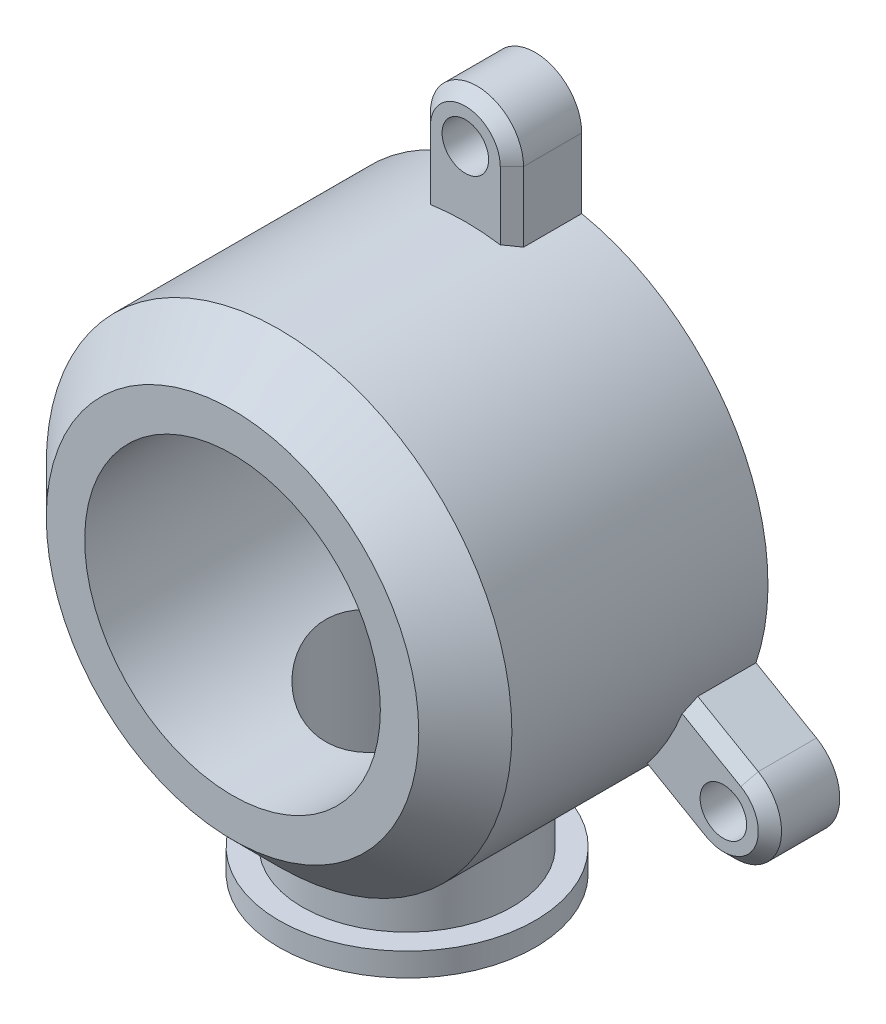
from build123d import *

# Parameters (mm, degrees)
BOSS_EXTRUDE1_DEPTH          = 65
BOSS_EXTRUDE2_DEPTH          = 25
BOSS_EXTRUDE3_DEPTH          = 15
CHAMFER2_SIZE                = 2.5
F_10_0MM_DOWEL_HOLE1_D       = 10
CIRPATTERN2_COUNT            = 3
CHAMFER2_OF_CIRPATTERN2_SIZE = 2.5
CHAMFER1_SIZE                = 10
SKETCH2_R                    = 27.5
BOSS_EXTRUDE4_DEPTH          = 5
BOSS_EXTRUDE5_REACH          = 164.658
SKETCH3_R                    = 22.5
CUT_EXTRUDE1_REACH           = 168.801
CUT_EXTRUDE1_END_RADIUS      = 31.75
SKETCH4_R                    = 17.5


with BuildPart() as part:
    # Sketch1 → Boss-Extrude1 (new body)
    with BuildSketch(Plane.XY):
        with BuildLine():
            ThreePointArc((10, 48.989794856), (0, 50), (-10, 48.989794856))
            ThreePointArc((-10, 48.989794856), (-31.622776602, -38.729833462), (50, 0))
            ThreePointArc((50, 0), (38.729833462, 31.622776602), (10, 48.989794856))
        make_face()
        with BuildLine():
            ThreePointArc((31.75, 0), (-20.607189279, -24.153804048), (-5, 31.353827518))
            ThreePointArc((-5, 31.353827518), (0, 31.75), (5, 31.353827518))
            ThreePointArc((5, 31.353827518), (24.153804048, 20.607189279), (31.75, 0))
        make_face(mode=Mode.SUBTRACT)
    extrude(amount=BOSS_EXTRUDE1_DEPTH)

    # Sketch1_3 → Boss-Extrude2 (add)
    with BuildSketch(Plane.XY):
        with BuildLine():
            Line((-5, 20.603827518), (5, 20.603827518))
            Line((5, 20.603827518), (5, 31.353827518))
            ThreePointArc((5, 31.353827518), (0, 31.75), (-5, 31.353827518))
            Line((-5, 31.353827518), (-5, 20.603827518))
        make_face()
    extrude(amount=BOSS_EXTRUDE2_DEPTH)

    # Sketch1_4 → Boss-Extrude3 (add)
    with BuildSketch(Plane.XY):
        with BuildLine():
            Line((-10, 63.989794856), (-10, 48.989794856))
            ThreePointArc((-10, 48.989794856), (0, 50), (10, 48.989794856))
            Line((10, 48.989794856), (10, 63.989794856))
            ThreePointArc((10, 63.989794856), (0, 73.989794856), (-10, 63.989794856))
        make_face()
    boss_extrude3 = extrude(amount=BOSS_EXTRUDE3_DEPTH)

    # Chamfer2
    chamfer2_edges = [part.edges().sort_by_distance(p)[0] for p in [
        (-10, 56.489794856, 15),
        (0, 73.989794856, 15),
        (10, 56.489794856, 15),
    ]]
    chamfer(chamfer2_edges, length=CHAMFER2_SIZE)

    # Ø10.0mm Dowel Hole1 (through all)
    with Locations(Plane.XY.offset(15)):
        with Locations((0, 63.989794856)):
            f_10_0mm_dowel_hole1 = Hole(F_10_0MM_DOWEL_HOLE1_D / 2)

    # CirPattern2: Boss-Extrude3, Ø10.0mm Dowel Hole1 ×3 about axis
    cirpattern2_axis = Axis((0, 0, 65), (0, 0, -1))
    add([boss_extrude3.rotate(cirpattern2_axis, i * 360 / CIRPATTERN2_COUNT) for i in range(1, CIRPATTERN2_COUNT)])
    add([f_10_0mm_dowel_hole1.rotate(cirpattern2_axis, i * 360 / CIRPATTERN2_COUNT) for i in range(1, CIRPATTERN2_COUNT)], mode=Mode.SUBTRACT)

    # Chamfer2 of CirPattern2
    chamfer2_of_cirpattern2_edges = [part.edges().sort_by_distance(p)[0] for p in [
        (53.9215974, -19.58464339, 15),
        (64.077041966, -36.994897428, 15),
        (43.9215974, -36.905151466, 15),
        (-43.9215974, -36.905151466, 15),
        (-64.077041966, -36.994897428, 15),
        (-53.9215974, -19.58464339, 15),
    ]]
    chamfer(chamfer2_of_cirpattern2_edges, length=CHAMFER2_OF_CIRPATTERN2_SIZE)

    # Chamfer1
    chamfer1_edges = [part.edges().sort_by_distance(p)[0] for p in [
        (-50, 0, 65),
    ]]
    chamfer(chamfer1_edges, length=CHAMFER1_SIZE)

    # Sketch3 → Boss-Extrude5 (add, up to next)
    with BuildSketch(Plane(origin=(0, -60, 0), x_dir=(1, 0, 0), z_dir=(0, 1, 0)), mode=Mode.PRIVATE) as boss_extrude5_sk1:
        with Locations((0, -27.5)):
            Circle(SKETCH3_R)
    boss_extrude5_tool1 = extrude(boss_extrude5_sk1.sketch, amount=BOSS_EXTRUDE5_REACH, mode=Mode.PRIVATE) - part.part


with BuildPart() as body_2:
    # Sketch2 → Boss-Extrude4 (new body)
    with BuildSketch(Plane(origin=(0, -65, 0), x_dir=(1, 0, 0), z_dir=(0, 1, 0))):
        with Locations((0, -27.5)):
            Circle(SKETCH2_R)
    extrude(amount=BOSS_EXTRUDE4_DEPTH)


with BuildPart() as part_1:
    add(part.part)

    add(body_2.part)  # Boss-Extrude5 merges body 2
    add(boss_extrude5_tool1.solids().sort_by_distance((0, -60, 27.5))[0])

    # Cut-Extrude1: up to this cylinder (the profile starts outside it)
    cut_extrude1_end = Plane(origin=(0, 0, 27.5), z_dir=(0, 0, -1)) * Cylinder(CUT_EXTRUDE1_END_RADIUS, 402.102, mode=Mode.PRIVATE)
    # Sketch4 → Cut-Extrude1 (cut, up to the surface)
    with BuildSketch(Plane.XZ.offset(65), mode=Mode.PRIVATE) as cut_extrude1_sk1:
        with Locations((0, 27.5)):
            Circle(SKETCH4_R)
    cut_extrude1_tool1 = extrude(cut_extrude1_sk1.sketch, amount=-CUT_EXTRUDE1_REACH, mode=Mode.PRIVATE) - cut_extrude1_end
    add(cut_extrude1_tool1.solids().sort_by_distance((0, -65, 27.5))[0], mode=Mode.SUBTRACT)


solid = part_1.part
